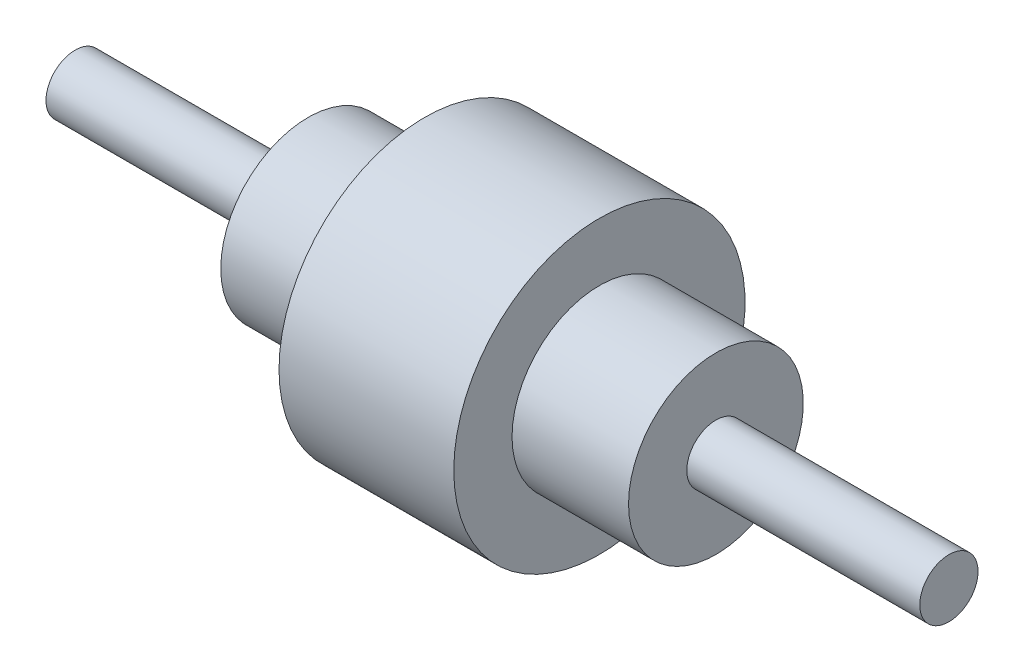
from build123d import *


with BuildPart() as part:
    # Sketch2 → Revolve1 (revolve)
    with BuildSketch(Plane(origin=(0, 0, 0), x_dir=(1, 0, 0), z_dir=(0, 1, 0)), mode=Mode.PRIVATE) as revolve1_sk:
        Polygon((30, 50), (-30, 50), (-30, 30), (-70, 30), (-70, 10), (-150, 10), (-150, 0), (150, 0), (150, 10), (70, 10), (70, 30), (30, 30), align=None)
    revolve(revolve1_sk.sketch.rotate(Axis((-169.638554217, 0, 0), (1, 0, 0)), 180), axis=Axis((-169.638554217, 0, 0), (1, 0, 0)))  # turned: the seam where the file's is


solid = part.part
